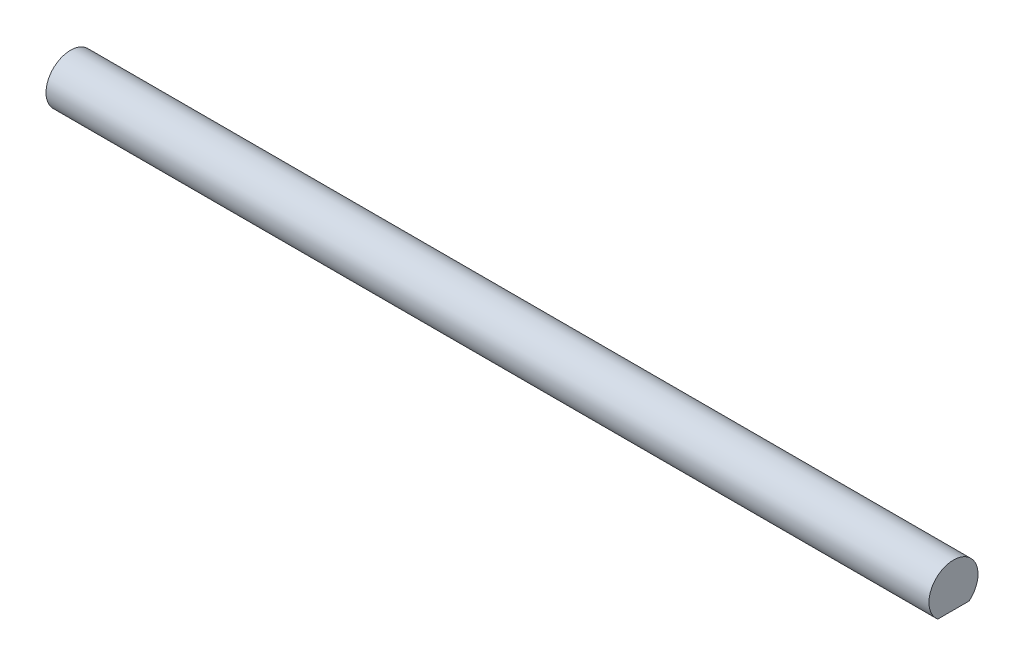
from build123d import *

# Parameters (mm, degrees)
BOSS_EXTRUDE1_DEPTH = 304.8
SKETCH2_R           = 3.175
CUT_EXTRUDE1_DEPTH  = 190.5


with BuildPart() as part:
    # Sketch1 → Boss-Extrude1 (new body)
    with BuildSketch(Plane(origin=(0, 0, 0), x_dir=(0, 0, -1), z_dir=(1, 0, 0))):
        with BuildLine():
            ThreePointArc((3.175, 0), (-1.347038418, 2.875084781), (-2.032, -2.439590334))
            Line((-2.032, -2.439590334), (2.032, -2.439590334))
            ThreePointArc((2.032, -2.439590334), (2.875084781, -1.347038418), (3.175, 0))
        make_face()
    extrude(amount=BOSS_EXTRUDE1_DEPTH)

    # Sketch2 → Cut-Extrude1 (cut)
    with BuildSketch(Plane(origin=(304.8, 0, 0), x_dir=(0, 0, -1), z_dir=(1, 0, 0))):
        Circle(SKETCH2_R)
    extrude(amount=-CUT_EXTRUDE1_DEPTH, mode=Mode.SUBTRACT)


solid = part.part
